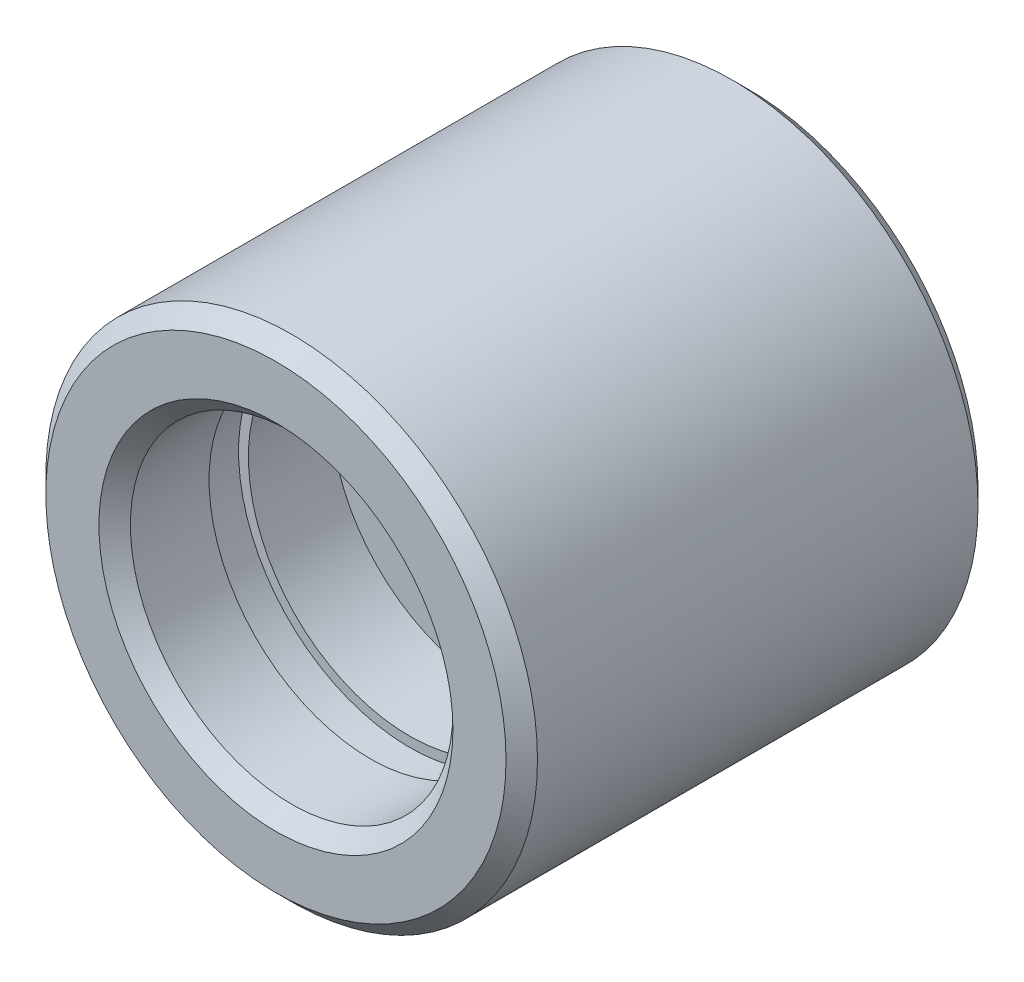
from build123d import *

# Parameters (mm, degrees)
SKETCH1_R           = 6.25
BOSS_EXTRUDE1_DEPTH = 12
CUT_EXTRUDE1_REACH  = 14
SKETCH2_R           = 1.5
SKETCH3_R           = 4.1
CUT_EXTRUDE2_DEPTH  = 5.5
SKETCH4_R           = 4.1
CUT_EXTRUDE3_DEPTH  = 5.5
SKETCH5_W           = 0.25
SKETCH5_H           = 1
CUT_EXTRUDE4_DEPTH  = 0.4
BOSS_EXTRUDE2_DEPTH = 0.2
CHAMFER1_SIZE       = 0.4


with BuildPart() as part:
    # Sketch1 → Boss-Extrude1 (new body)
    with BuildSketch(Plane.XY):
        Circle(SKETCH1_R)
    extrude(amount=BOSS_EXTRUDE1_DEPTH)

    # Sketch2 → Cut-Extrude1 (cut, up to next)
    with BuildSketch(Plane.XY.offset(12), mode=Mode.PRIVATE) as cut_extrude1_sk1:
        Circle(SKETCH2_R)
    cut_extrude1_tool1 = extrude(cut_extrude1_sk1.sketch, amount=-CUT_EXTRUDE1_REACH, mode=Mode.PRIVATE) & part.part
    add(cut_extrude1_tool1.solids().sort_by_distance((0, 0, 12))[0], mode=Mode.SUBTRACT)

    # Sketch3 → Cut-Extrude2 (cut)
    with BuildSketch(Plane.XY.offset(12)):
        Circle(SKETCH3_R)
    extrude(amount=-CUT_EXTRUDE2_DEPTH, mode=Mode.SUBTRACT)

    # Sketch4 → Cut-Extrude3 (cut)
    with BuildSketch(Plane(origin=(0, 0, 0), x_dir=(-1, 0, 0), z_dir=(0, 0, -1))):
        Circle(SKETCH4_R)
    extrude(amount=-CUT_EXTRUDE3_DEPTH, mode=Mode.SUBTRACT)

    # Sketch5 → Cut-Revolve1 (revolve, cut)
    with BuildSketch(Plane(origin=(0, 0, 0), x_dir=(1, 0, 0), z_dir=(0, 1, 0))):
        with Locations((4.225, -2.9)):
            Rectangle(SKETCH5_W, SKETCH5_H)
        with Locations((4.225, -9.1)):
            Rectangle(SKETCH5_W, SKETCH5_H)
    revolve(axis=Axis((0, 0, 12), (0, 0, -1)), mode=Mode.SUBTRACT)

    # Sketch6 → Cut-Extrude4 (cut)
    with BuildSketch(Plane(origin=(0, 0, 5.5), x_dir=(-1, 0, 0), z_dir=(0, 0, -1))):
        with BuildLine():
            ThreePointArc((-3.815756806, 1.5), (-4.1, 0), (-3.815756806, -1.5))
            Line((-3.815756806, -1.5), (0, -1.5))
            ThreePointArc((0, -1.5), (-1.5, 0), (0, 1.5))
            Line((0, 1.5), (-3.815756806, 1.5))
        make_face()
        with BuildLine():
            ThreePointArc((1.5, 0), (1.060660172, -1.060660172), (0, -1.5))
            Line((0, -1.5), (3.815756806, -1.5))
            ThreePointArc((3.815756806, -1.5), (4.028312482, -0.763346938), (4.1, 0))
            ThreePointArc((4.1, 0), (4.028312482, 0.763346938), (3.815756806, 1.5))
            Line((3.815756806, 1.5), (0, 1.5))
            ThreePointArc((0, 1.5), (1.060660172, 1.060660172), (1.5, 0))
        make_face()
    extrude(amount=-CUT_EXTRUDE4_DEPTH, mode=Mode.SUBTRACT)

    # Sketch7 → Boss-Extrude2 (add)
    with BuildSketch(Plane(origin=(0, 0, 5.9), x_dir=(-1, 0, 0), z_dir=(0, 0, -1))):
        with BuildLine():
            Line((-1.5, 0), (-1.5, 1.5))
            Line((-1.5, 1.5), (-3.815756806, 1.5))
            ThreePointArc((-3.815756806, 1.5), (-4.1, 0), (-3.815756806, -1.5))
            Line((-3.815756806, -1.5), (-1.5, -1.5))
            Line((-1.5, -1.5), (-1.5, 0))
        make_face()
        with BuildLine():
            ThreePointArc((3.815756806, -1.5), (4.1, 0), (3.815756806, 1.5))
            Line((3.815756806, 1.5), (1.5, 1.5))
            Line((1.5, 1.5), (1.5, 0))
            Line((1.5, 0), (1.5, -1.5))
            Line((1.5, -1.5), (3.815756806, -1.5))
        make_face()
    extrude(amount=BOSS_EXTRUDE2_DEPTH)

    # Chamfer1
    chamfer1_edges = [part.edges().sort_by_distance(p)[0] for p in [
        (-4.1, 0, 12),
        (4.1, 0, 0),
        (-6.25, 0, 0),
        (-6.25, 0, 12),
    ]]
    chamfer(chamfer1_edges, length=CHAMFER1_SIZE)


solid = part.part
